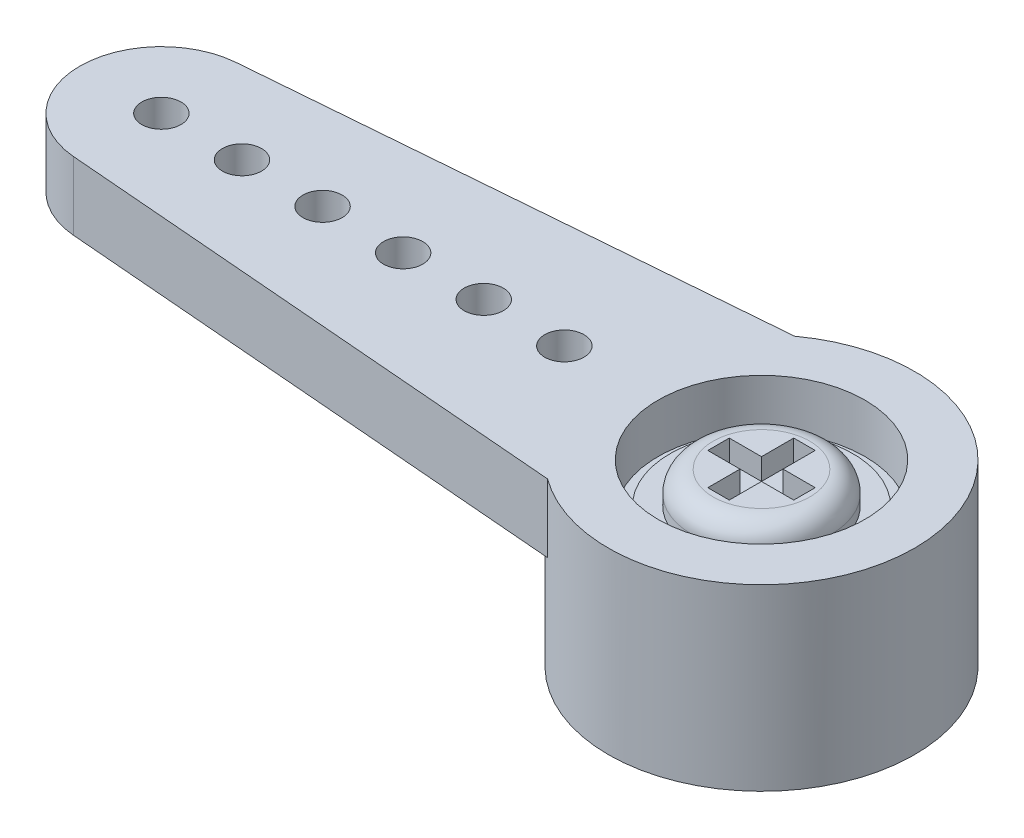
from build123d import *

# Parameters (mm, degrees)
EXTRUDE17_DEPTH = 1.6129
SKETCH19_R      = 3.6195
EXTRUDE19_DEPTH = 4.2291
SKETCH20_R      = 0.46355
SKETCH20_R_2    = 1.27
EXTRUDE20_DEPTH = 18.050548166
SKETCH21_R      = 2.44475
EXTRUDE21_DEPTH = 1.1557
SKETCH22_R      = 2.286
EXTRUDE22_DEPTH = 2.3368
SKETCH23_R      = 2.159
EXTRUDE23_DEPTH = 0.2032
SKETCH24_R      = 1.651
EXTRUDE24_DEPTH = 0.762
EXTRUDE25_DEPTH = 0.508
FILLET1_R       = 0.508


with BuildPart() as part:
    # Sketch18 → Extrude17 (new body)
    with BuildSketch(Plane(origin=(0, 0, 0), x_dir=(1, 0, 0), z_dir=(0, 1, 0))):
        with BuildLine():
            Line((-14.34305969, 1.923991942), (-2.13741415, 2.921))
            ThreePointArc((-2.13741415, 2.921), (3.6195, 0), (-2.13741415, -2.921))
            Line((-2.13741415, -2.921), (-14.34305969, -1.923991942))
            ThreePointArc((-14.34305969, -1.923991942), (-16.1163, 0), (-14.34305969, 1.923991942))
        make_face()
    extrude(amount=EXTRUDE17_DEPTH)

    # Sketch19 → Extrude19 (add)
    with BuildSketch(Plane(origin=(0, 1.6129, 0), x_dir=(1, 0, 0), z_dir=(0, 1, 0))):
        with Locations(Location((0, 0, 0), (0, 0, 126.194447475))):
            Circle(SKETCH19_R)
    extrude(amount=-EXTRUDE19_DEPTH)

    # Sketch20 → Extrude20 (cut, through all)
    with BuildSketch(Plane(origin=(0, 1.6129, 0), x_dir=(1, 0, 0), z_dir=(0, 1, 0))):
        with Locations(Location((-14.1859, 0, 0), (0, 0, 270))):
            Circle(SKETCH20_R)
        with Locations(Location((0, 0, 0), (0, 0, 270))):
            Circle(SKETCH20_R_2)
        with Locations(Location((-4.6609, 0, 0), (0, 0, 270))):
            Circle(SKETCH20_R)
        with Locations(Location((-6.5659, 0, 0), (0, 0, 270))):
            Circle(SKETCH20_R)
        with Locations(Location((-8.4709, 0, 0), (0, 0, 270))):
            Circle(SKETCH20_R)
        with Locations(Location((-10.3759, 0, 0), (0, 0, 270))):
            Circle(SKETCH20_R)
        with Locations(Location((-12.2809, 0, 0), (0, 0, 270))):
            Circle(SKETCH20_R)
    extrude(amount=-EXTRUDE20_DEPTH, mode=Mode.SUBTRACT)

    # Sketch21 → Extrude21 (cut)
    with BuildSketch(Plane(origin=(0, 1.6129, 0), x_dir=(1, 0, 0), z_dir=(0, 1, 0))):
        with Locations(Location((0, 0, 0), (0, 0, 270))):
            Circle(SKETCH21_R)
    extrude(amount=-EXTRUDE21_DEPTH, mode=Mode.SUBTRACT)

    # Sketch22 → Extrude22 (cut)
    with BuildSketch(Plane.XZ.offset(2.6162)):
        with Locations(Location((0, 0, 0), (0, 0, 270))):
            Circle(SKETCH22_R)
    extrude(amount=-EXTRUDE22_DEPTH, mode=Mode.SUBTRACT)



with BuildPart() as body_2:
    # Sketch23 → Extrude23 (new body)
    with BuildSketch(Plane(origin=(0, 0.4572, 0), x_dir=(1, 0, 0), z_dir=(0, 1, 0))):
        with Locations(Location((0, 0, 0), (0, 0, 270))):
            Circle(SKETCH23_R)
    extrude(amount=EXTRUDE23_DEPTH)


with BuildPart() as part_1:
    add(part.part)

    add(body_2.part)  # Extrude24 merges body 2
    # Sketch24 → Extrude24 (add)
    with BuildSketch(Plane(origin=(0, 0.6604, 0), x_dir=(1, 0, 0), z_dir=(0, 1, 0))):
        with Locations(Location((0, 0, 0), (0, 0, 90))):
            Circle(SKETCH24_R)
    extrude(amount=EXTRUDE24_DEPTH)

    # Sketch25 → Extrude25 (cut)
    with BuildSketch(Plane(origin=(0, 1.4224, 0), x_dir=(1, 0, 0), z_dir=(0, 1, 0))):
        Polygon((0.254, -1.016), (-0.254, -1.016), (-0.254, -0.254), (-1.016, -0.254), (-1.016, 0.254), (-0.254, 0.254), (-0.254, 1.016), (0.254, 1.016), (0.254, 0.254), (1.016, 0.254), (1.016, -0.254), (0.254, -0.254), align=None)
    extrude(amount=-EXTRUDE25_DEPTH, mode=Mode.SUBTRACT)

    # Fillet1
    fillet1_edges = [part_1.edges().sort_by_distance(p)[0] for p in [
        (0, 1.4224, 1.651),
    ]]
    fillet(fillet1_edges, radius=FILLET1_R)


solid = part_1.part
